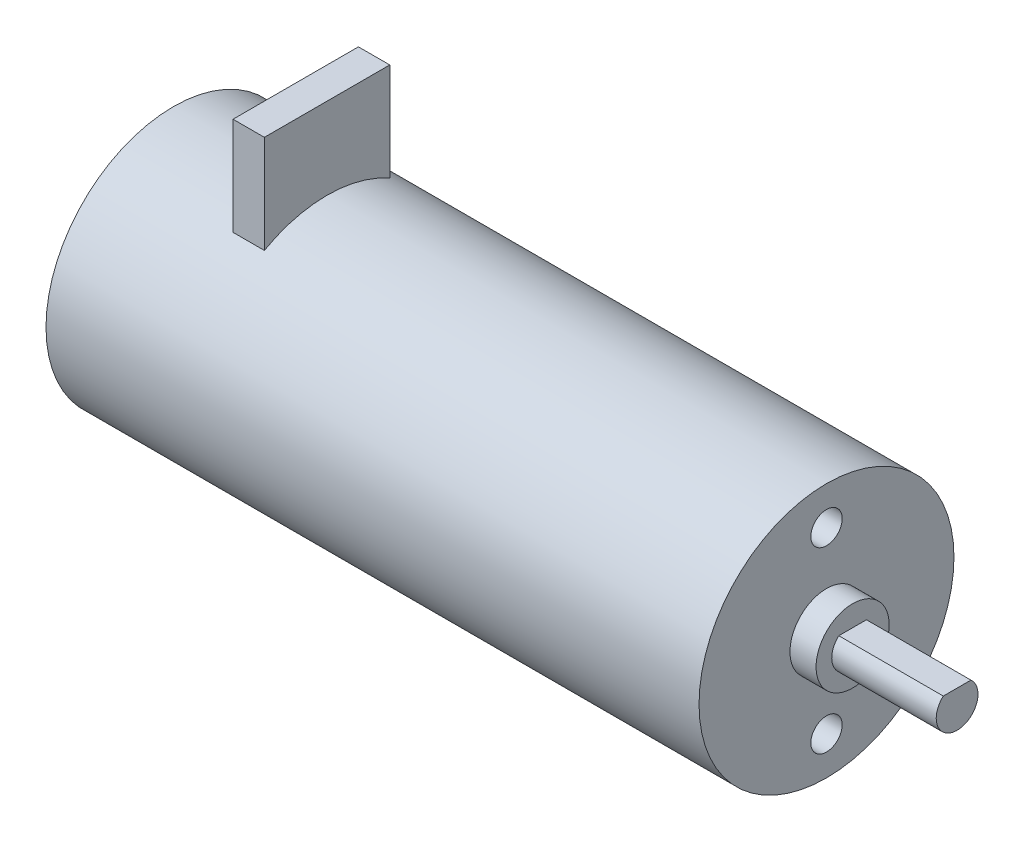
from build123d import *

# Parameters (mm, degrees)
SKETCH1_R           = 12.2
BOSS_EXTRUDE1_DEPTH = 62.5
SKETCH2_R           = 3.5
BOSS_EXTRUDE2_DEPTH = 2.5
BOSS_EXTRUDE3_DEPTH = 10
SKETCH4_R           = 1.5
CUT_EXTRUDE1_DEPTH  = 5
SKETCH5_W           = 3
SKETCH5_H           = 12
BOSS_EXTRUDE4_DEPTH = 20


with BuildPart() as part:
    # Sketch1 → Boss-Extrude1 (new body)
    with BuildSketch(Plane(origin=(0, 0, 0), x_dir=(0, 0, -1), z_dir=(1, 0, 0))):
        Circle(SKETCH1_R)
    extrude(amount=BOSS_EXTRUDE1_DEPTH)

    # Sketch2 → Boss-Extrude2 (add)
    with BuildSketch(Plane(origin=(62.5, 0, 0), x_dir=(0, 0, -1), z_dir=(1, 0, 0))):
        Circle(SKETCH2_R)
    extrude(amount=BOSS_EXTRUDE2_DEPTH)

    # Sketch3 → Boss-Extrude3 (add)
    with BuildSketch(Plane(origin=(65, 0, 0), x_dir=(0, 0, -1), z_dir=(1, 0, 0))):
        with BuildLine():
            Line((-1.322875656, 1.5), (1.322875656, 1.5))
            ThreePointArc((1.322875656, 1.5), (0, -2), (-1.322875656, 1.5))
        make_face()
    extrude(amount=BOSS_EXTRUDE3_DEPTH)

    # Sketch4 → Cut-Extrude1 (cut)
    with BuildSketch(Plane(origin=(62.5, 0, 0), x_dir=(0, 0, -1), z_dir=(1, 0, 0))):
        with Locations((0, 8.55)):
            Circle(SKETCH4_R)
        with Locations((0, -8.55)):
            Circle(SKETCH4_R)
    extrude(amount=-CUT_EXTRUDE1_DEPTH, mode=Mode.SUBTRACT)

    # Sketch5 → Boss-Extrude4 (add)
    with BuildSketch(Plane(origin=(0, 0, 0), x_dir=(1, 0, 0), z_dir=(0, 1, 0))):
        with Locations((13.2, 0)):
            Rectangle(SKETCH5_W, SKETCH5_H)
    extrude(amount=BOSS_EXTRUDE4_DEPTH)


solid = part.part
